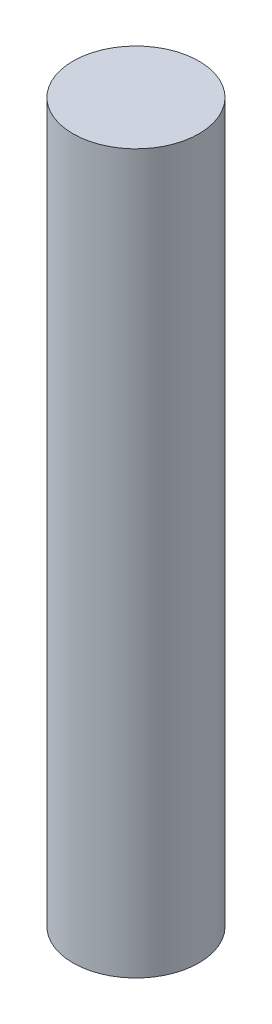
from build123d import *

# Parameters (mm, degrees)
IZIM1_R                     = 5
Y_KSEKLIK_EKSTR_ZYON1_DEPTH = 57


with BuildPart() as part:
    # Çizim1 → Yükseklik-Ekstrüzyon1 (new body)
    with BuildSketch(Plane(origin=(0, 0, 0), x_dir=(1, 0, 0), z_dir=(0, 1, 0))):
        Circle(IZIM1_R)
    extrude(amount=Y_KSEKLIK_EKSTR_ZYON1_DEPTH)


solid = part.part
